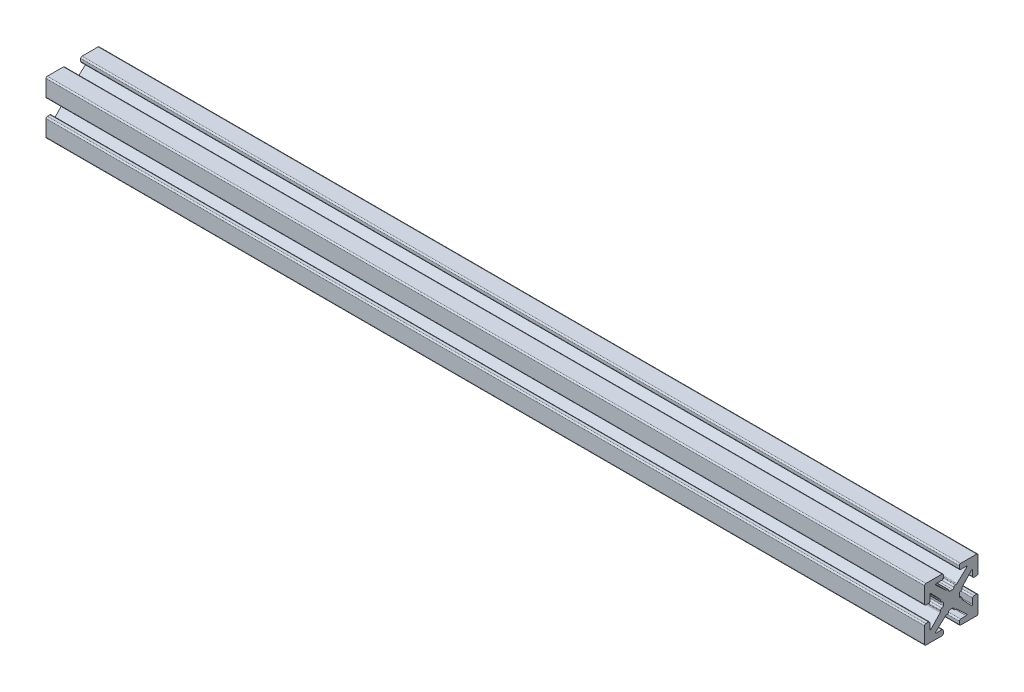
from build123d import *

# Parameters (mm, degrees)
BOSS_EXTRU_1_DEPTH = 164.48


with BuildPart() as part:
    # Sketch1 → Boss.-Extru.1 (new body)
    with BuildSketch(Plane(origin=(0, 0, 0), x_dir=(0, 0, -1), z_dir=(1, 0, 0))):
        with BuildLine():
            Line((-0.2413, 1.4986), (0.2413, 1.4986))
            ThreePointArc((0.2413, 1.4986), (0.420905122, 1.572994878), (0.4953, 1.7526))
            ThreePointArc((0.4953, 1.7526), (0.569694878, 1.932205122), (0.7493, 2.0066))
            Line((0.7493, 2.0066), (0.889923986, 2.0066))
            ThreePointArc((0.889923986, 2.0066), (0.983516259, 2.024471886), (1.063937899, 2.075572548))
            Line((1.063937899, 2.075572548), (2.890793, 3.793686274))
            ThreePointArc((2.890793, 3.793686274), (2.921850101, 3.932996137), (2.803786044, 4.0132))
            Line((2.803786044, 4.0132), (1.7526, 4.0132))
            ThreePointArc((1.7526, 4.0132), (1.572994878, 4.087594878), (1.4986, 4.2672))
            Line((1.4986, 4.2672), (1.4986, 4.7498))
            ThreePointArc((1.4986, 4.7498), (1.572994878, 4.929405122), (1.7526, 5.0038))
            Line((1.7526, 5.0038), (4.7498, 5.0038))
            ThreePointArc((4.7498, 5.0038), (4.929405122, 4.929405122), (5.0038, 4.7498))
            Line((5.0038, 4.7498), (5.0038, 1.7526))
            ThreePointArc((5.0038, 1.7526), (4.929405122, 1.572994878), (4.7498, 1.4986))
            Line((4.7498, 1.4986), (4.2672, 1.4986))
            ThreePointArc((4.2672, 1.4986), (4.087594878, 1.572994878), (4.0132, 1.7526))
            Line((4.0132, 1.7526), (4.0132, 2.803786044))
            ThreePointArc((4.0132, 2.803786044), (3.932996137, 2.921850101), (3.793686274, 2.890793))
            Line((3.793686274, 2.890793), (2.075572548, 1.063937899))
            ThreePointArc((2.075572548, 1.063937899), (2.024471886, 0.983516259), (2.0066, 0.889923986))
            Line((2.0066, 0.889923986), (2.0066, 0.7493))
            ThreePointArc((2.0066, 0.7493), (1.932205122, 0.569694878), (1.7526, 0.4953))
            ThreePointArc((1.7526, 0.4953), (1.572994878, 0.420905122), (1.4986, 0.2413))
            Line((1.4986, 0.2413), (1.4986, -0.2413))
            ThreePointArc((1.4986, -0.2413), (1.572994878, -0.420905122), (1.7526, -0.4953))
            ThreePointArc((1.7526, -0.4953), (1.932205122, -0.569694878), (2.0066, -0.7493))
            Line((2.0066, -0.7493), (2.0066, -0.889923986))
            ThreePointArc((2.0066, -0.889923986), (2.024471886, -0.983516259), (2.075572548, -1.063937899))
            Line((2.075572548, -1.063937899), (3.793686274, -2.890793))
            ThreePointArc((3.793686274, -2.890793), (3.932996137, -2.921850101), (4.0132, -2.803786044))
            Line((4.0132, -2.803786044), (4.0132, -1.7526))
            ThreePointArc((4.0132, -1.7526), (4.087594878, -1.572994878), (4.2672, -1.4986))
            Line((4.2672, -1.4986), (4.7498, -1.4986))
            ThreePointArc((4.7498, -1.4986), (4.929405122, -1.572994878), (5.0038, -1.7526))
            Line((5.0038, -1.7526), (5.0038, -4.7498))
            ThreePointArc((5.0038, -4.7498), (4.929405122, -4.929405122), (4.7498, -5.0038))
            Line((4.7498, -5.0038), (1.7526, -5.0038))
            ThreePointArc((1.7526, -5.0038), (1.572994878, -4.929405122), (1.4986, -4.7498))
            Line((1.4986, -4.7498), (1.4986, -4.2672))
            ThreePointArc((1.4986, -4.2672), (1.572994878, -4.087594878), (1.7526, -4.0132))
            Line((1.7526, -4.0132), (2.803786044, -4.0132))
            ThreePointArc((2.803786044, -4.0132), (2.921850101, -3.932996137), (2.890793, -3.793686274))
            Line((2.890793, -3.793686274), (1.063937899, -2.075572548))
            ThreePointArc((1.063937899, -2.075572548), (0.983516259, -2.024471886), (0.889923986, -2.0066))
            Line((0.889923986, -2.0066), (0.7493, -2.0066))
            ThreePointArc((0.7493, -2.0066), (0.569694878, -1.932205122), (0.4953, -1.7526))
            ThreePointArc((0.4953, -1.7526), (0.420905122, -1.572994878), (0.2413, -1.4986))
            Line((0.2413, -1.4986), (-0.2413, -1.4986))
            ThreePointArc((-0.2413, -1.4986), (-0.420905122, -1.572994878), (-0.4953, -1.7526))
            ThreePointArc((-0.4953, -1.7526), (-0.569694878, -1.932205122), (-0.7493, -2.0066))
            Line((-0.7493, -2.0066), (-0.889923986, -2.0066))
            ThreePointArc((-0.889923986, -2.0066), (-0.983516259, -2.024471886), (-1.063937899, -2.075572548))
            Line((-1.063937899, -2.075572548), (-2.890793, -3.793686274))
            ThreePointArc((-2.890793, -3.793686274), (-2.921850101, -3.932996137), (-2.803786044, -4.0132))
            Line((-2.803786044, -4.0132), (-1.7526, -4.0132))
            ThreePointArc((-1.7526, -4.0132), (-1.572994878, -4.087594878), (-1.4986, -4.2672))
            Line((-1.4986, -4.2672), (-1.4986, -4.7498))
            ThreePointArc((-1.4986, -4.7498), (-1.572994878, -4.929405122), (-1.7526, -5.0038))
            Line((-1.7526, -5.0038), (-4.7498, -5.0038))
            ThreePointArc((-4.7498, -5.0038), (-4.929405122, -4.929405122), (-5.0038, -4.7498))
            Line((-5.0038, -4.7498), (-5.0038, -1.7526))
            ThreePointArc((-5.0038, -1.7526), (-4.929405122, -1.572994878), (-4.7498, -1.4986))
            Line((-4.7498, -1.4986), (-4.2672, -1.4986))
            ThreePointArc((-4.2672, -1.4986), (-4.087594878, -1.572994878), (-4.0132, -1.7526))
            Line((-4.0132, -1.7526), (-4.0132, -2.803786044))
            ThreePointArc((-4.0132, -2.803786044), (-3.932996137, -2.921850101), (-3.793686274, -2.890793))
            Line((-3.793686274, -2.890793), (-2.075572548, -1.063937899))
            ThreePointArc((-2.075572548, -1.063937899), (-2.024471886, -0.983516259), (-2.0066, -0.889923986))
            Line((-2.0066, -0.889923986), (-2.0066, -0.7493))
            ThreePointArc((-2.0066, -0.7493), (-1.932205122, -0.569694878), (-1.7526, -0.4953))
            ThreePointArc((-1.7526, -0.4953), (-1.572994878, -0.420905122), (-1.4986, -0.2413))
            Line((-1.4986, -0.2413), (-1.4986, 0.2413))
            ThreePointArc((-1.4986, 0.2413), (-1.572994878, 0.420905122), (-1.7526, 0.4953))
            ThreePointArc((-1.7526, 0.4953), (-1.932205122, 0.569694878), (-2.0066, 0.7493))
            Line((-2.0066, 0.7493), (-2.0066, 0.889923986))
            ThreePointArc((-2.0066, 0.889923986), (-2.024471886, 0.983516259), (-2.075572548, 1.063937899))
            Line((-2.075572548, 1.063937899), (-3.793686274, 2.890793))
            ThreePointArc((-3.793686274, 2.890793), (-3.932996137, 2.921850101), (-4.0132, 2.803786044))
            Line((-4.0132, 2.803786044), (-4.0132, 1.7526))
            ThreePointArc((-4.0132, 1.7526), (-4.087594878, 1.572994878), (-4.2672, 1.4986))
            Line((-4.2672, 1.4986), (-4.7498, 1.4986))
            ThreePointArc((-4.7498, 1.4986), (-4.929405122, 1.572994878), (-5.0038, 1.7526))
            Line((-5.0038, 1.7526), (-5.0038, 4.7498))
            ThreePointArc((-5.0038, 4.7498), (-4.929405122, 4.929405122), (-4.7498, 5.0038))
            Line((-4.7498, 5.0038), (-1.7526, 5.0038))
            ThreePointArc((-1.7526, 5.0038), (-1.572994878, 4.929405122), (-1.4986, 4.7498))
            Line((-1.4986, 4.7498), (-1.4986, 4.2672))
            ThreePointArc((-1.4986, 4.2672), (-1.572994878, 4.087594878), (-1.7526, 4.0132))
            Line((-1.7526, 4.0132), (-2.803786044, 4.0132))
            ThreePointArc((-2.803786044, 4.0132), (-2.921850101, 3.932996137), (-2.890793, 3.793686274))
            Line((-2.890793, 3.793686274), (-1.063937899, 2.075572548))
            ThreePointArc((-1.063937899, 2.075572548), (-0.983516259, 2.024471886), (-0.889923986, 2.0066))
            Line((-0.889923986, 2.0066), (-0.7493, 2.0066))
            ThreePointArc((-0.7493, 2.0066), (-0.569694878, 1.932205122), (-0.4953, 1.7526))
            ThreePointArc((-0.4953, 1.7526), (-0.420905122, 1.572994878), (-0.2413, 1.4986))
        make_face()
    extrude(amount=BOSS_EXTRU_1_DEPTH)


solid = part.part
